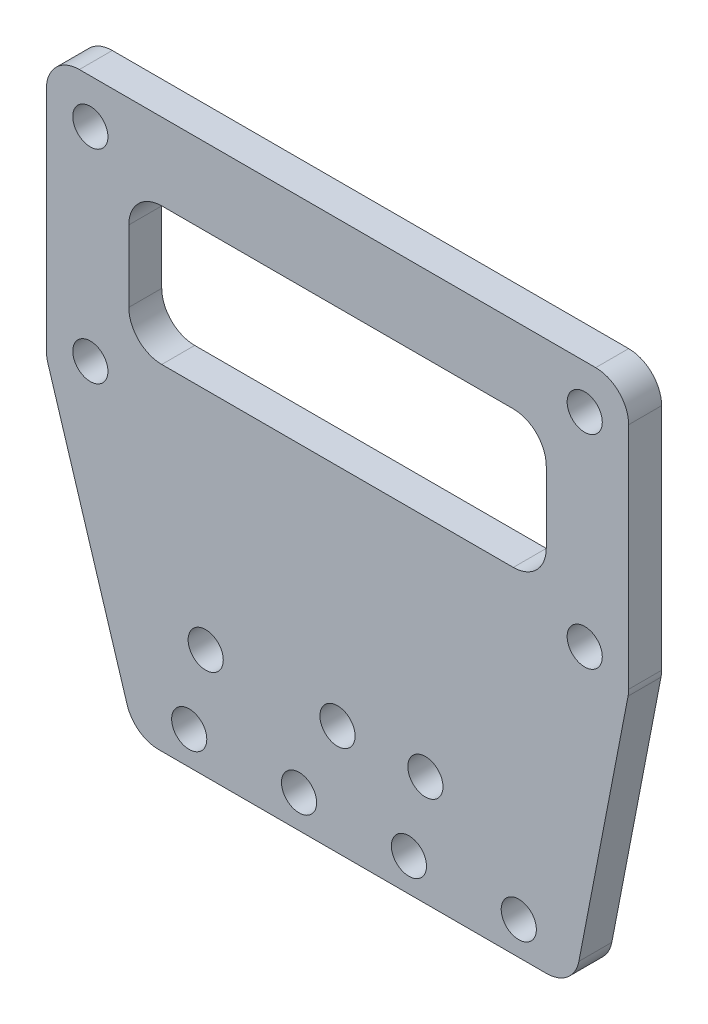
from build123d import *

# Parameters (mm, degrees)
SKETCH_1_R          = 1.6
EXTRUDE_1_DEPTH     = 3
SKETCH_2_R          = 1.6
CUT_EXTRUDE_1_DEPTH = 4
SKETCH_3_R          = 1.6
CUT_EXTRUDE_2_DEPTH = 4
SKETCH_4_W          = 38
SKETCH_4_H          = 12.5
CUT_EXTRUDE_3_DEPTH = 4
FILLET_1_R          = 3


with BuildPart() as part:
    # 草图1 → 凸台-拉伸1 (new body)
    with BuildSketch(Plane.XY):
        Polygon((-40, 0), (-48, 25.855555556), (-48, 50), (5, 50), (5, 25.855555556), (0, 0), align=None)
        with Locations((-44, 46)):
            Circle(SKETCH_1_R, mode=Mode.SUBTRACT)
        with Locations((1, 46)):
            Circle(SKETCH_1_R, mode=Mode.SUBTRACT)
        with Locations((1, 27.5)):
            Circle(SKETCH_1_R, mode=Mode.SUBTRACT)
        with Locations((-44, 27.5)):
            Circle(SKETCH_1_R, mode=Mode.SUBTRACT)
    extrude(amount=EXTRUDE_1_DEPTH)

    # 草图2 → 切除-拉伸1 (cut, through all)
    with BuildSketch(Plane.XY.offset(3)):
        with Locations((-5, 3)):
            Circle(SKETCH_2_R)
        with Locations((-15, 3)):
            Circle(SKETCH_2_R)
        with Locations((-25, 3)):
            Circle(SKETCH_2_R)
        with Locations((-35, 3)):
            Circle(SKETCH_2_R)
    extrude(amount=-CUT_EXTRUDE_1_DEPTH, mode=Mode.SUBTRACT)

    # 草图3 → 切除-拉伸2 (cut, through all)
    with BuildSketch(Plane.XY.offset(3)):
        with Locations((-13.5, 10)):
            Circle(SKETCH_3_R)
        with Locations((-21.5, 10)):
            Circle(SKETCH_3_R)
        with Locations((-33.5, 10)):
            Circle(SKETCH_3_R)
        with Locations((-21.5, 34)):
            Circle(SKETCH_3_R)
    extrude(amount=-CUT_EXTRUDE_2_DEPTH, mode=Mode.SUBTRACT)

    # 草图4 → 切除-拉伸3 (cut, through all)
    with BuildSketch(Plane.XY.offset(3)):
        with Locations((-21.5, 36.75)):
            Rectangle(SKETCH_4_W, SKETCH_4_H)
    extrude(amount=-CUT_EXTRUDE_3_DEPTH, mode=Mode.SUBTRACT)

    # 圆角1
    fillet_1_edges = [part.edges().sort_by_distance(p)[0] for p in [
        (0, 0, 1.5),
        (-40, 0, 1.5),
        (-48, 25.855555556, 1.5),
        (-48, 50, 1.5),
        (5, 50, 1.5),
        (5, 25.855555556, 1.5),
        (-2.5, 43, 1.5),
        (-2.5, 30.5, 1.5),
        (-40.5, 30.5, 1.5),
        (-40.5, 43, 1.5),
    ]]
    fillet(fillet_1_edges, radius=FILLET_1_R)


solid = part.part
